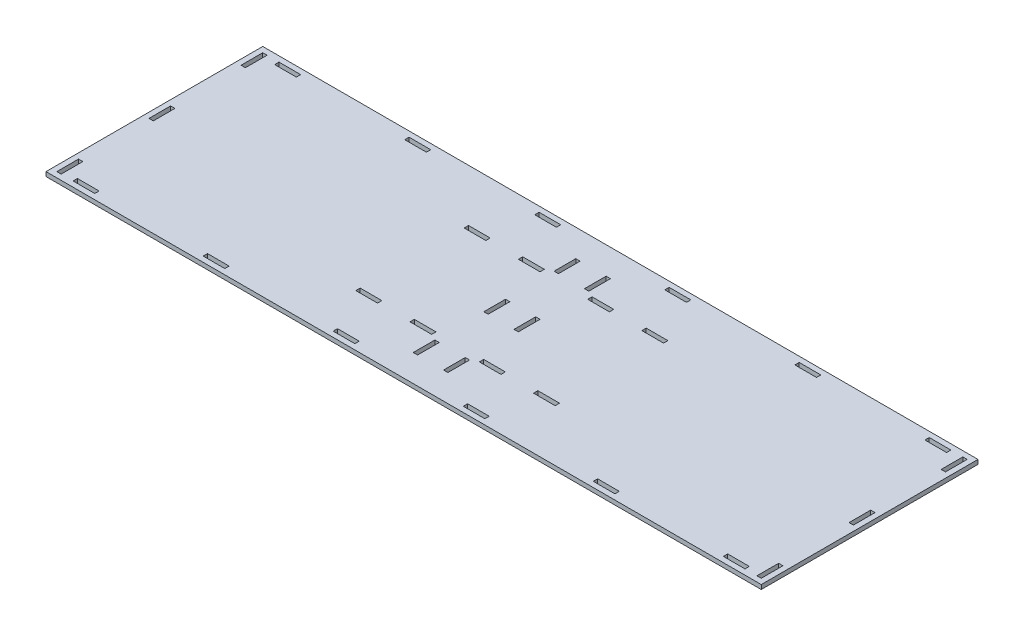
from build123d import *

# Parameters (mm, degrees)
SKETCH1_W           = 660
SKETCH1_H           = 200
SKETCH1_W_2         = 20
SKETCH1_H_2         = 4
SKETCH1_W_3         = 4
SKETCH1_H_3         = 20
BOSS_EXTRUDE1_DEPTH = 4


with BuildPart() as part:
    # Sketch1 → Boss-Extrude1 (new body)
    with BuildSketch(Plane(origin=(0, 0, 0), x_dir=(1, 0, 0), z_dir=(0, 1, 0))):
        Rectangle(SKETCH1_W, SKETCH1_H)
        with Locations((-82, 49.859697176)):
            Rectangle(SKETCH1_W_2, SKETCH1_H_2, mode=Mode.SUBTRACT)
        with Locations((-32, 49.859697176)):
            Rectangle(SKETCH1_W_2, SKETCH1_H_2, mode=Mode.SUBTRACT)
        with Locations((-82, -50.140302824)):
            Rectangle(SKETCH1_W_2, SKETCH1_H_2, mode=Mode.SUBTRACT)
        with Locations((-32, -50.140302824)):
            Rectangle(SKETCH1_W_2, SKETCH1_H_2, mode=Mode.SUBTRACT)
        with Locations((-14, 64.859697176)):
            Rectangle(SKETCH1_W_3, SKETCH1_H_3, mode=Mode.SUBTRACT)
        with Locations((14, 64.859697176)):
            Rectangle(SKETCH1_W_3, SKETCH1_H_3, mode=Mode.SUBTRACT)
        with Locations((32, 49.859697176)):
            Rectangle(SKETCH1_W_2, SKETCH1_H_2, mode=Mode.SUBTRACT)
        with Locations((82, 49.859697176)):
            Rectangle(SKETCH1_W_2, SKETCH1_H_2, mode=Mode.SUBTRACT)
        with Locations((-14, 0)):
            Rectangle(SKETCH1_W_3, SKETCH1_H_3, mode=Mode.SUBTRACT)
        with Locations((14, -0.140302824)):
            Rectangle(SKETCH1_W_3, SKETCH1_H_3, mode=Mode.SUBTRACT)
        with Locations((32, -50.140302824)):
            Rectangle(SKETCH1_W_2, SKETCH1_H_2, mode=Mode.SUBTRACT)
        with Locations((14, -65.140302824)):
            Rectangle(SKETCH1_W_3, SKETCH1_H_3, mode=Mode.SUBTRACT)
        with Locations((82, -50.140302824)):
            Rectangle(SKETCH1_W_2, SKETCH1_H_2, mode=Mode.SUBTRACT)
        with Locations((-323, -85)):
            Rectangle(SKETCH1_W_3, SKETCH1_H_3, mode=Mode.SUBTRACT)
        with Locations((-323, 85)):
            Rectangle(SKETCH1_W_3, SKETCH1_H_3, mode=Mode.SUBTRACT)
        with Locations((323, -85)):
            Rectangle(SKETCH1_W_3, SKETCH1_H_3, mode=Mode.SUBTRACT)
        with Locations((-323, 0)):
            Rectangle(SKETCH1_W_3, SKETCH1_H_3, mode=Mode.SUBTRACT)
        with Locations((323, 0)):
            Rectangle(SKETCH1_W_3, SKETCH1_H_3, mode=Mode.SUBTRACT)
        with Locations((323, 85)):
            Rectangle(SKETCH1_W_3, SKETCH1_H_3, mode=Mode.SUBTRACT)
        with Locations((-300, 93)):
            Rectangle(SKETCH1_W_2, SKETCH1_H_2, mode=Mode.SUBTRACT)
        with Locations((-180, 93)):
            Rectangle(SKETCH1_W_2, SKETCH1_H_2, mode=Mode.SUBTRACT)
        with Locations((-60, 93)):
            Rectangle(SKETCH1_W_2, SKETCH1_H_2, mode=Mode.SUBTRACT)
        with Locations((300, 93)):
            Rectangle(SKETCH1_W_2, SKETCH1_H_2, mode=Mode.SUBTRACT)
        with Locations((-14, -65.140302824)):
            Rectangle(SKETCH1_W_3, SKETCH1_H_3, mode=Mode.SUBTRACT)
        with Locations((180, 93)):
            Rectangle(SKETCH1_W_2, SKETCH1_H_2, mode=Mode.SUBTRACT)
        with Locations((60, 93)):
            Rectangle(SKETCH1_W_2, SKETCH1_H_2, mode=Mode.SUBTRACT)
        with Locations((300, -93)):
            Rectangle(SKETCH1_W_2, SKETCH1_H_2, mode=Mode.SUBTRACT)
        with Locations((180, -93)):
            Rectangle(SKETCH1_W_2, SKETCH1_H_2, mode=Mode.SUBTRACT)
        with Locations((60, -93)):
            Rectangle(SKETCH1_W_2, SKETCH1_H_2, mode=Mode.SUBTRACT)
        with Locations((-60, -93)):
            Rectangle(SKETCH1_W_2, SKETCH1_H_2, mode=Mode.SUBTRACT)
        with Locations((-180, -93)):
            Rectangle(SKETCH1_W_2, SKETCH1_H_2, mode=Mode.SUBTRACT)
        with Locations((-300, -93)):
            Rectangle(SKETCH1_W_2, SKETCH1_H_2, mode=Mode.SUBTRACT)
    extrude(amount=BOSS_EXTRUDE1_DEPTH)


solid = part.part
